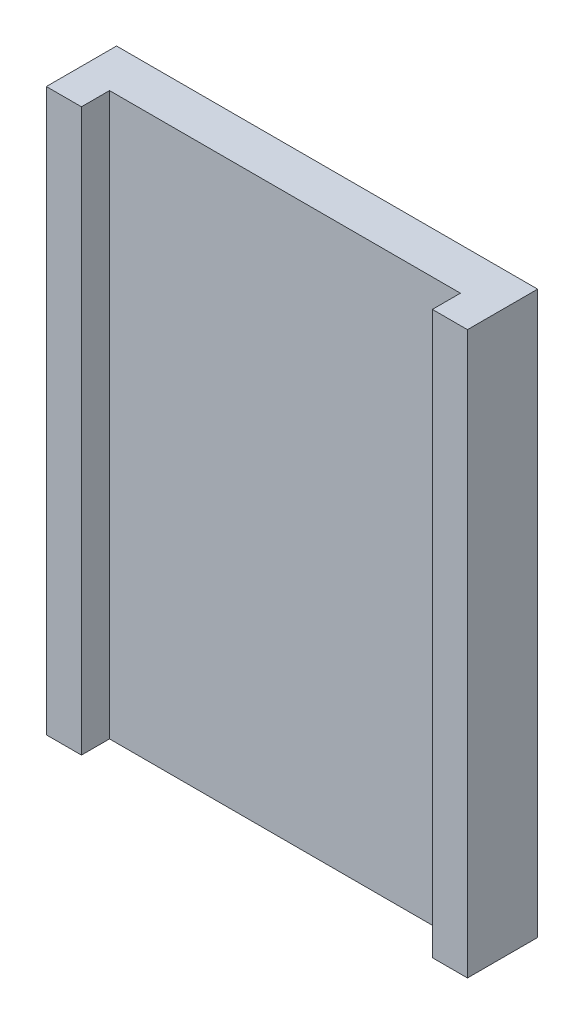
from build123d import *

# Parameters (mm, degrees)
SKETCH1_W           = 6.25
SKETCH1_H           = 10
BOSS_EXTRUDE1_DEPTH = 0.75
SKETCH1_3_W         = 0.625
SKETCH1_3_H         = 10
BOSS_EXTRUDE2_DEPTH = 1.25


with BuildPart() as part:
    # Sketch1 → Boss-Extrude1 (new body)
    with BuildSketch(Plane.XY):
        Rectangle(SKETCH1_W, SKETCH1_H)
    extrude(amount=BOSS_EXTRUDE1_DEPTH)

    # Sketch1_3 → Boss-Extrude2 (add)
    with BuildSketch(Plane.XY):
        with Locations((-3.4375, 0)):
            Rectangle(SKETCH1_3_W, SKETCH1_3_H)
        with Locations((3.4375, 0)):
            Rectangle(SKETCH1_3_W, SKETCH1_3_H)
    extrude(amount=BOSS_EXTRUDE2_DEPTH)


solid = part.part
